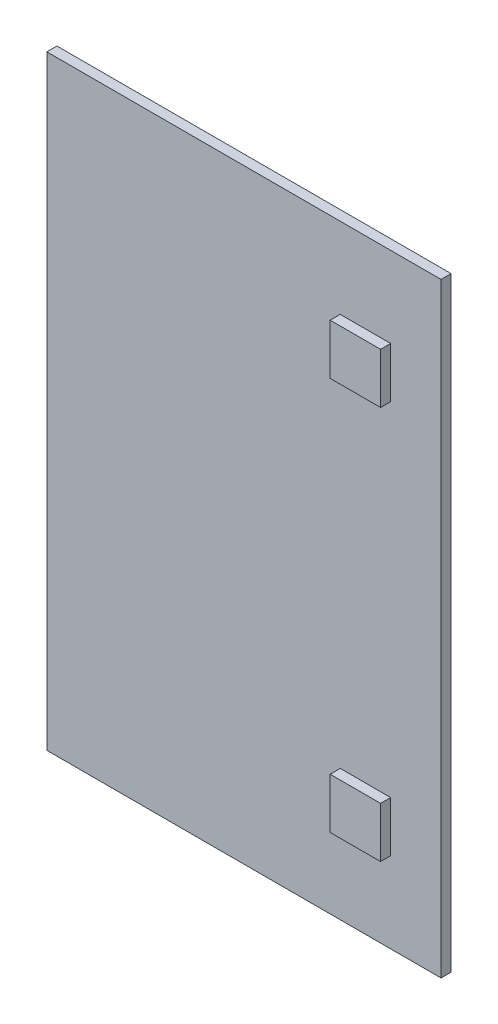
from build123d import *

# Parameters (mm, degrees)
ESQUISSE1_W        = 391
ESQUISSE1_H        = 600
BOSS_EXTRU_1_DEPTH = 10
ESQUISSE2_W        = 50
ESQUISSE2_H        = 50
BOSS_EXTRU_2_DEPTH = 10


with BuildPart() as part:
    # Esquisse1 → Boss.-Extru.1 (new body)
    with BuildSketch(Plane.XY):
        with Locations((-214.094107131, 299.546616829)):
            Rectangle(ESQUISSE1_W, ESQUISSE1_H)
    extrude(amount=-BOSS_EXTRU_1_DEPTH)

    # Esquisse2 → Boss.-Extru.2 (add)
    with BuildSketch(Plane.XY):
        with Locations((-93.594107131, 494.546616829)):
            Rectangle(ESQUISSE2_W, ESQUISSE2_H)
        with Locations((-93.594107131, 104.546616829)):
            Rectangle(ESQUISSE2_W, ESQUISSE2_H)
    extrude(amount=BOSS_EXTRU_2_DEPTH)


solid = part.part
